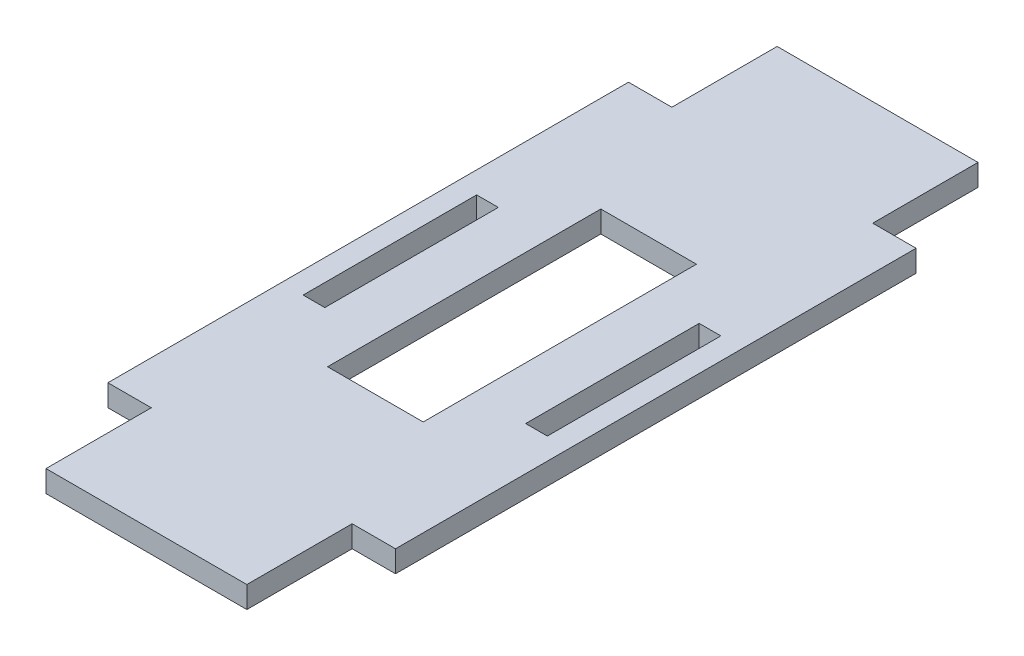
from build123d import *

# Parameters (mm, degrees)
SKETCH1_W           = 14
SKETCH1_H           = 40
BOSS_EXTRUDE1_DEPTH = 3.175


with BuildPart() as part:
    # Sketch1 → Boss-Extrude1 (new body)
    with BuildSketch(Plane(origin=(0, 0, 0), x_dir=(1, 0, 0), z_dir=(0, 1, 0))):
        Polygon((-17.875, -38.1), (-14.7, -38.1), (-14.7, -53.51285), (14.7, -53.51285), (14.7, -38.1), (17.875, -38.1), (17.875, -12.7), (14.7, -12.7), (14.7, 12.7), (17.875, 12.7), (17.875, 38.1), (14.7, 38.1), (14.7, 53.51285), (-14.7, 53.51285), (-14.7, 38.1), (-17.875, 38.1), (-17.875, 12.7), (-14.7, 12.7), (-14.7, -12.7), (-17.875, -12.7), align=None)
        Rectangle(SKETCH1_W, SKETCH1_H, mode=Mode.SUBTRACT)
        Polygon((-21.05, -38.1), (-17.875, -38.1), (-17.875, -12.7), (-17.875, 12.7), (-17.875, 38.1), (-21.05, 38.1), align=None)
        Polygon((17.875, -12.7), (17.875, -38.1), (21.05, -38.1), (21.05, 38.1), (17.875, 38.1), (17.875, 12.7), align=None)
    extrude(amount=BOSS_EXTRUDE1_DEPTH)


solid = part.part
